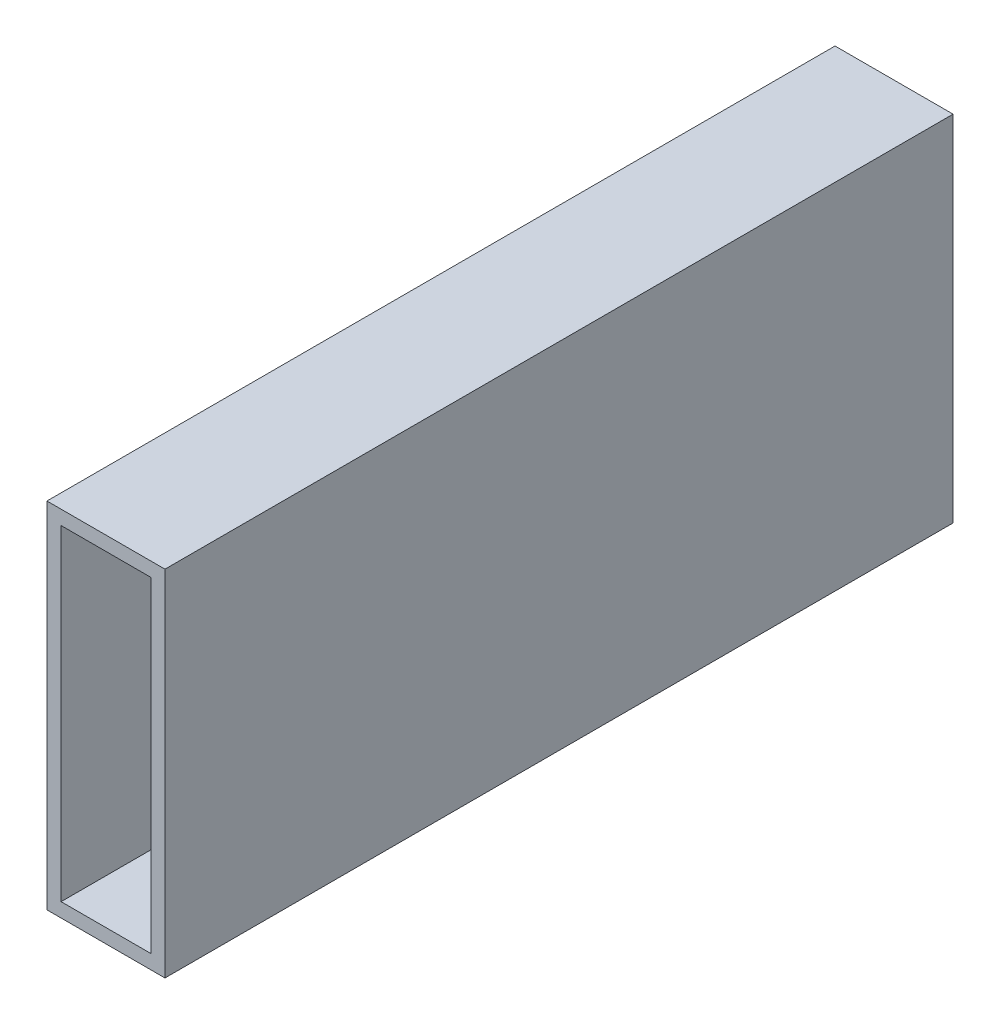
from build123d import *

# Parameters (mm, degrees)
SKETCH2_W               = 9.652
SKETCH2_H               = 3.048
SKETCH2_W_2             = 3.048
SKETCH2_H_2             = 35.052
BOSS_EXTRUDE1_DEPTH     = 195
CUT_EXTRUDE1_DEPTH      = 323.7
CUT_EXTRUDE1_DEPTH_BACK = 1


with BuildPart() as part:
    # Sketch2 → Boss-Extrude1 (new body)
    with BuildSketch(Plane.XY):
        Polygon((-12.7, 0), (-9.652, 0), (-9.652, 35.052), (-9.652, 38.1), (-12.7, 38.1), align=None)
        with Locations((-4.826, 36.576)):
            Rectangle(SKETCH2_W, SKETCH2_H)
        Polygon((0, 38.1), (0, 35.052), (9.652, 35.052), (9.652, 0), (12.7, 0), (12.7, 38.1), align=None)
        with Locations((11.176, -17.526)):
            Rectangle(SKETCH2_W_2, SKETCH2_H_2)
        Polygon((-9.652, -35.052), (-9.652, 0), (-12.7, 0), (-12.7, -38.1), (0, -38.1), (0, -35.052), align=None)
        Polygon((9.652, -35.052), (0, -35.052), (0, -38.1), (12.7, -38.1), (12.7, -35.052), align=None)
    extrude(amount=BOSS_EXTRUDE1_DEPTH)

    # Sketch3 → Cut-Extrude1 (cut, two sides)
    with BuildSketch(Plane(origin=(310, 0, 195), x_dir=(0, 0, 1), z_dir=(-1, 0, 0))) as cut_extrude1_sk:
        Polygon((-12.7, -38.1), (-12.7, 38.1), (12.7, 38.1), align=None)
        Polygon((12.7, -38.1), (-12.7, -38.1), (12.7, 38.1), align=None)
        Polygon((-182.3, 38.1), (-207.7, 38.1), (-207.7, -38.1), align=None)
        Polygon((-182.3, -38.1), (-207.7, -38.1), (-182.3, 38.1), align=None)
    extrude(amount=CUT_EXTRUDE1_DEPTH, mode=Mode.SUBTRACT)
    extrude(cut_extrude1_sk.sketch, amount=-CUT_EXTRUDE1_DEPTH_BACK, mode=Mode.SUBTRACT)


solid = part.part
